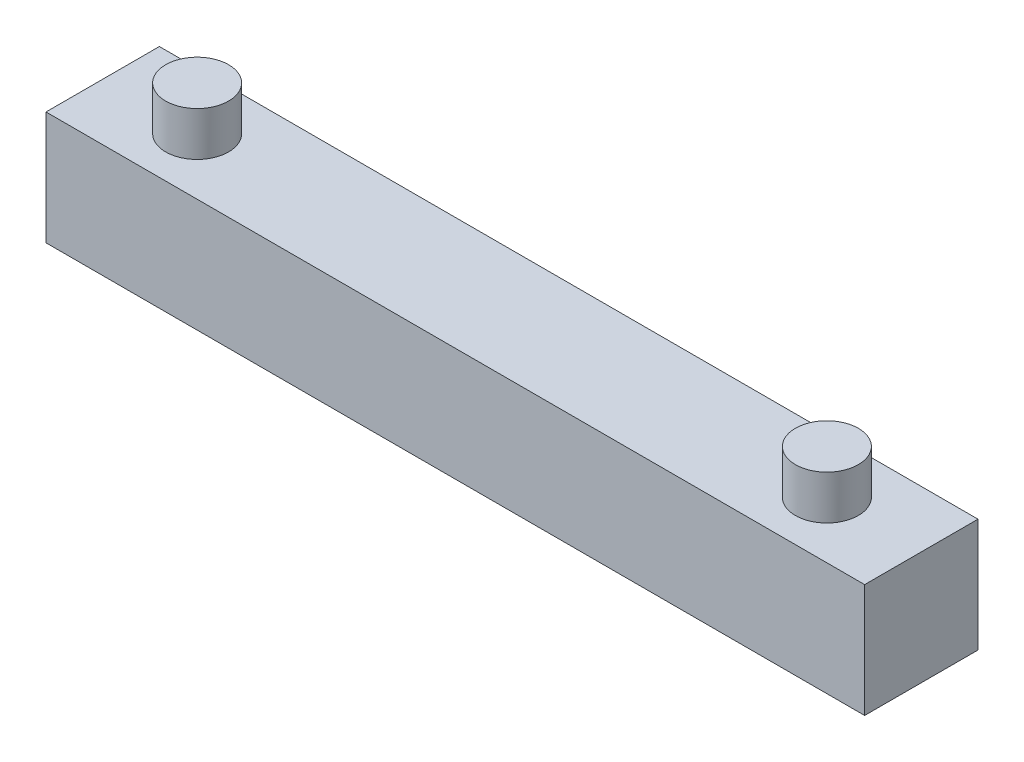
from build123d import *

# Parameters (mm, degrees)
SKETCH1_W           = 65
SKETCH1_H           = 9
BOSS_EXTRUDE1_DEPTH = 9
SKETCH2_R           = 2.5
BOSS_EXTRUDE2_DEPTH = 3.5


with BuildPart() as part:
    # Sketch1 → Boss-Extrude1 (new body)
    with BuildSketch(Plane.XY):
        with Locations((32.5, 4.5)):
            Rectangle(SKETCH1_W, SKETCH1_H)
    extrude(amount=BOSS_EXTRUDE1_DEPTH)

    # Sketch2 → Boss-Extrude2 (add)
    with BuildSketch(Plane(origin=(0, 9, 0), x_dir=(1, 0, 0), z_dir=(0, 1, 0))):
        with Locations(Location((7.5, -4.5, 0), (0, 0, 90))):  # turned: the seam where the file's is
            Circle(SKETCH2_R)
        with Locations(Location((57.5, -4.5, 0), (0, 0, 90))):  # turned: the seam where the file's is
            Circle(SKETCH2_R)
    extrude(amount=BOSS_EXTRUDE2_DEPTH)


solid = part.part
